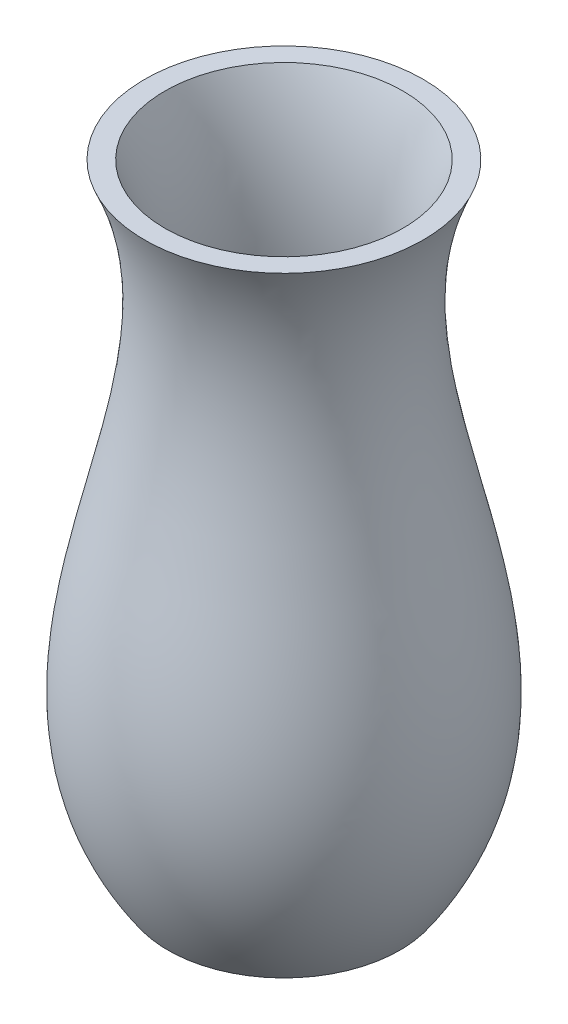
from build123d import *


with BuildPart() as part:
    # Sketch1 → Revolve1 (revolve)
    with BuildSketch(Plane.XY):
        with BuildLine():
            Line((0, 0), (25, 0))
            add(Edge.make_bspline(
                [(25, 0), (56.398358551, 45.077660663), (9.307176018, 89.395493607), (30, 135)],
                knots=[0, 0, 0, 0, 1, 1, 1, 1], degree=3))
            Line((30, 135), (25.634896862, 135))
            add(Edge.make_bspline(
                [(21.717744664, 2.286219568), (22.17410939, 2.941408411), (23.071781004, 4.281724892), (24.698929207, 6.920023214), (26.47970086, 10.214764374), (28.226713031, 14.145803438), (30.082017277, 19.375181203), (31.581398794, 25.906377431), (32.27338388, 33.797885185), (32.040110234, 41.782038081), (30.737647037, 52.570111715), (27.720142097, 66.321789494), (24.204012322, 80.406315163), (21.96227447, 91.892342395), (20.795301867, 100.626445363), (20.379241641, 109.486432062), (20.863041994, 116.970187044), (21.871237784, 123.003735677), (22.966764382, 127.545063938), (24.187377509, 131.340874035), (25.145247632, 133.822074392), (25.547373753, 134.79185494), (25.634896862, 135)],
                knots=[0, 0, 0, 0, 0.015625, 0.03125, 0.0625, 0.09375, 0.125, 0.1875, 0.25, 0.3125, 0.375, 0.5, 0.625, 0.6875, 0.75, 0.8125, 0.875, 0.90625, 0.9375, 0.96875, 0.984375, 0.988646412, 0.988646412, 0.988646412, 0.988646412], degree=3))
            Line((21.717744664, 2.286219568), (0, 2.286219568))
            Line((0, 2.286219568), (0, 0))
        make_face()
    revolve(axis=Axis((0, 0, 0), (0, 1, 0)))


solid = part.part
